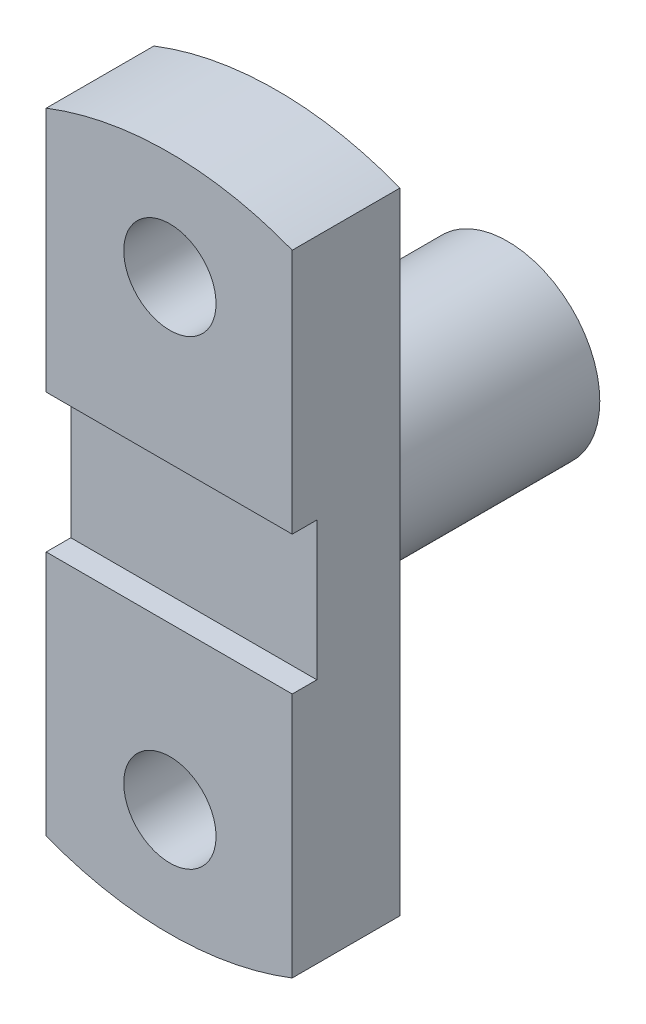
from build123d import *

# Parameters (mm, degrees)
SKETCH1_R           = 15
BOSS_EXTRUDE1_DEPTH = 35
SKETCH2_W           = 8
SKETCH2_H           = 45
CUT_EXTRUDE1_DEPTH  = 85
SKETCH3_R           = 30
BOSS_EXTRUDE2_DEPTH = 75


with BuildPart() as part:
    # Sketch1 → Boss-Extrude1 (new body)
    with BuildSketch(Plane.XY):
        with BuildLine():
            Line((40, -102.46950766), (40, 102.46950766))
            ThreePointArc((40, 102.46950766), (0, 110), (-40, 102.46950766))
            Line((-40, 102.46950766), (-40, -102.46950766))
            ThreePointArc((-40, -102.46950766), (0, -110), (40, -102.46950766))
        make_face()
        with Locations((0.217775187, 75)):
            Circle(SKETCH1_R, mode=Mode.SUBTRACT)
        with Locations((0.217775187, -75)):
            Circle(SKETCH1_R, mode=Mode.SUBTRACT)
    extrude(amount=BOSS_EXTRUDE1_DEPTH)

    # Sketch2 → Cut-Extrude1 (cut)
    with BuildSketch(Plane(origin=(40, 0, 0), x_dir=(0, 0, -1), z_dir=(1, 0, 0))):
        with Locations((-31, 0)):
            Rectangle(SKETCH2_W, SKETCH2_H)
    extrude(amount=-CUT_EXTRUDE1_DEPTH, mode=Mode.SUBTRACT)

    # Sketch3 → Boss-Extrude2 (add)
    with BuildSketch(Plane(origin=(0, 0, 0), x_dir=(-1, 0, 0), z_dir=(0, 0, -1))):
        Circle(SKETCH3_R)
    extrude(amount=BOSS_EXTRUDE2_DEPTH)


solid = part.part
